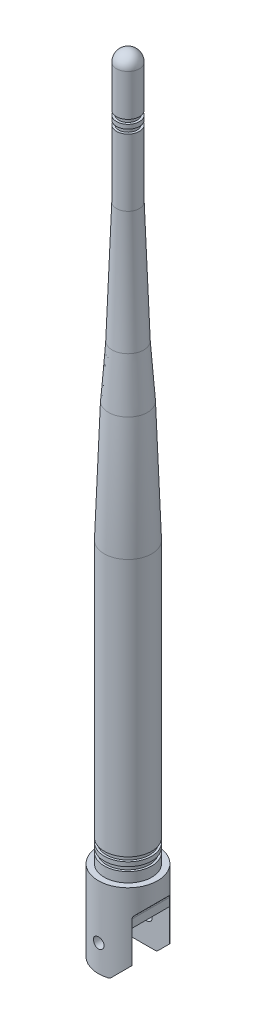
from build123d import *

# Parameters (mm, degrees)
SKETCH3_R               = 7
BOSS_EXTRUDE1_DEPTH     = 19
SKETCH4_W               = 8.92
SKETCH4_H               = 10.7
CUT_EXTRUDE1_DEPTH      = 9
CUT_EXTRUDE1_DEPTH_BACK = 4.46
SKETCH5_R               = 1.25
CUT_EXTRUDE2_DEPTH      = 14.46
CUT_EXTRUDE2_DEPTH_BACK = 14.46
FILLET1_R               = 1


with BuildPart() as part:
    # Sketch1 → Revolve1 (revolve)
    with BuildSketch(Plane.XY):
        with BuildLine():
            Line((0, 0), (-5.6, 0))
            Line((-5.6, 0), (-5.6, 2.32))
            Line((-5.6, 2.32), (-5.095, 2.32))
            Line((-5.095, 2.32), (-5.095, 3.32))
            Line((-5.095, 3.32), (-5.6, 3.32))
            Line((-5.6, 3.32), (-5.6, 4.32))
            Line((-5.6, 4.32), (-5.095, 4.32))
            Line((-5.095, 4.32), (-5.095, 5.32))
            Line((-5.095, 5.32), (-5.6, 5.32))
            Line((-5.6, 5.32), (-5.6, 66.104936914))
            ThreePointArc((-5.6, 66.104936914), (-5.347653972, 80.311032213), (-4.590934282, 94.499203254))
            Line((-4.590934282, 94.499203254), (-3.714065718, 106.820796746))
            ThreePointArc((-3.714065718, 106.820796746), (-2.957346028, 121.008967787), (-2.705, 135.215063086))
            Line((-2.705, 135.215063086), (-2.705, 151))
            Line((-2.705, 151), (-2.17, 151))
            Line((-2.17, 151), (-2.17, 152))
            Line((-2.17, 152), (-2.705, 152))
            Line((-2.705, 152), (-2.705, 153))
            Line((-2.705, 153), (-2.17, 153))
            Line((-2.17, 153), (-2.17, 154))
            Line((-2.17, 154), (-2.705, 154))
            Line((-2.705, 154), (-2.705, 163.795))
            ThreePointArc((-2.705, 163.795), (-1.912723843, 165.707723843), (0, 166.5))
            Line((0, 166.5), (0, 0))
        make_face()
    revolve(axis=Axis((0, 0, 0), (0, 1, 0)))

    # Sketch3 → Boss-Extrude1 (add)
    with BuildSketch(Plane.XZ):
        Circle(SKETCH3_R)
    extrude(amount=BOSS_EXTRUDE1_DEPTH)

    # Sketch4 → Cut-Extrude1 (cut, two sides)
    with BuildSketch(Plane(origin=(0, 0, 0), x_dir=(0, 0, -1), z_dir=(1, 0, 0))) as cut_extrude1_sk:
        with Locations((0, -13.65)):
            Rectangle(SKETCH4_W, SKETCH4_H)
    extrude(amount=CUT_EXTRUDE1_DEPTH, mode=Mode.SUBTRACT)
    extrude(cut_extrude1_sk.sketch, amount=-CUT_EXTRUDE1_DEPTH_BACK, mode=Mode.SUBTRACT)

    # Sketch5 → Cut-Extrude2 (cut, two sides)
    with BuildSketch(Plane.XY) as cut_extrude2_sk:
        with Locations((0, -12.7)):
            Circle(SKETCH5_R)
        Polygon((5.395220107, -6), (5.395220107, -15.933988373), (0.784672068, -20.544536411), (9.016530708, -20.544536411), (9.016530708, -2.378689399), align=None)
    extrude(amount=CUT_EXTRUDE2_DEPTH, mode=Mode.SUBTRACT)
    extrude(cut_extrude2_sk.sketch, amount=-CUT_EXTRUDE2_DEPTH_BACK, mode=Mode.SUBTRACT)

    # Fillet1
    fillet1_edges = [part.edges().sort_by_distance(p)[0] for p in [
        (5.395220107, -6, 0),
        (2.329208479, -19, -5.530560099),
        (2.329208479, -19, 5.530560099),
        (-4.46, -13.65, -4.46),
        (-4.46, -13.65, 4.46),
    ]]
    fillet(fillet1_edges, radius=FILLET1_R)


solid = part.part
